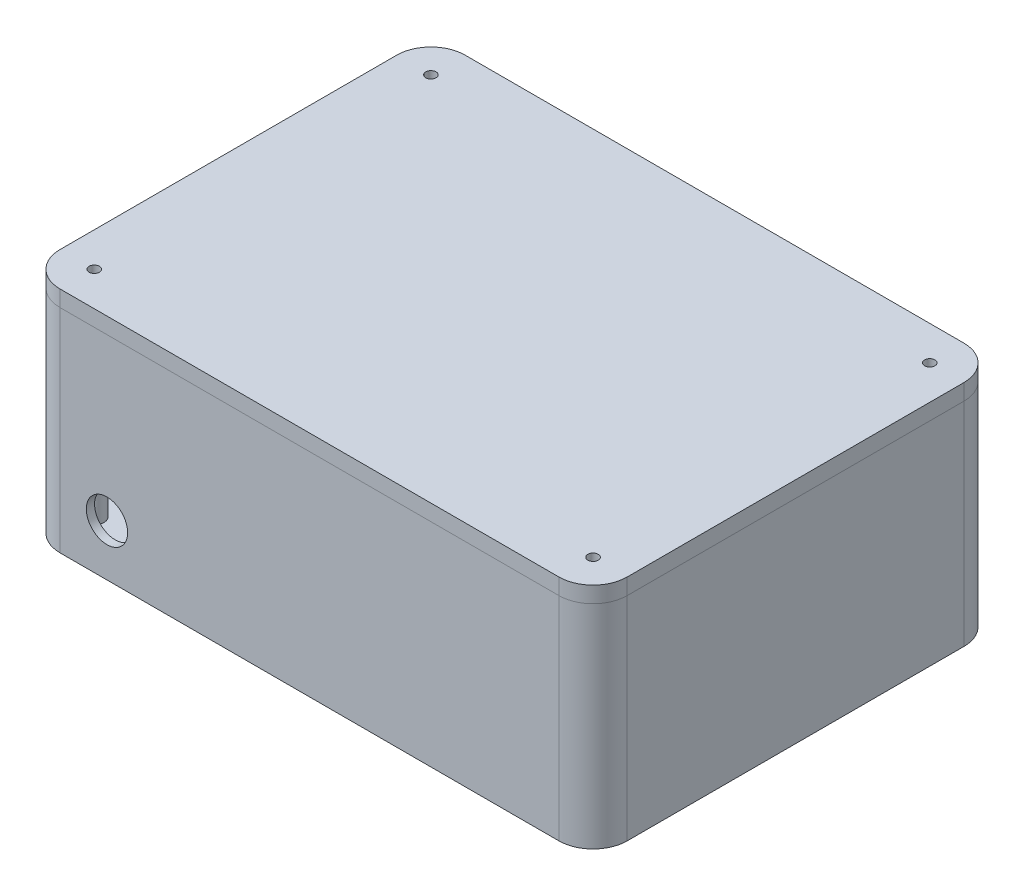
from build123d import *

# Parameters (mm, degrees)
SIDES_DEPTH        = 60.96
SKETCH1_R          = 2.9845
SKETCH1_R_2        = 1.5875
SIDES_2_DEPTH      = 60.96
SIDES_3_DEPTH      = 60.96
SIDES_4_DEPTH      = 60.96
SIDES_5_DEPTH      = 60.96
BOTTOM_DEPTH       = 4.318
SKETCH3_R          = 1.5875
LID_DEPTH          = 4.953
SKETCH6_R          = 1.778
MX150_CUTS_DEPTH   = 2.54
SKETCH7_R          = 6.35
CUT_EXTRUDE1_DEPTH = 2.54


with BuildPart() as part:
    # Sketch1 → Sides (new body)
    with BuildSketch(Plane(origin=(0, 0, 0), x_dir=(1, 0, 0), z_dir=(0, 1, 0))):
        with BuildLine():
            Line((-76.6347, 62.23), (76.6347, 62.23))
            ThreePointArc((76.6347, 62.23), (84.059321202, 59.154621202), (87.1347, 51.73))
            Line((87.1347, 51.73), (87.1347, -51.73))
            ThreePointArc((87.1347, -51.73), (84.059321202, -59.154621202), (76.6347, -62.23))
            Line((76.6347, -62.23), (-76.6347, -62.23))
            ThreePointArc((-76.6347, -62.23), (-84.059321202, -59.154621202), (-87.1347, -51.73))
            Line((-87.1347, -51.73), (-87.1347, 51.73))
            ThreePointArc((-87.1347, 51.73), (-84.059321202, 59.154621202), (-76.6347, 62.23))
        make_face()
        with BuildLine():
            ThreePointArc((-76.6347, 59.69), (-82.263269978, 57.358569978), (-84.5947, 51.73))
            Line((-84.5947, 51.73), (-84.5947, -51.73))
            ThreePointArc((-84.5947, -51.73), (-82.263269978, -57.358569978), (-76.6347, -59.69))
            Line((-76.6347, -59.69), (76.6347, -59.69))
            ThreePointArc((76.6347, -59.69), (82.263269978, -57.358569978), (84.5947, -51.73))
            Line((84.5947, -51.73), (84.5947, 51.73))
            ThreePointArc((84.5947, 51.73), (82.263269978, 57.358569978), (76.6347, 59.69))
            Line((76.6347, 59.69), (-76.6347, 59.69))
        make_face(mode=Mode.SUBTRACT)
    extrude(amount=SIDES_DEPTH)

    # Sketch2 → Bottom (add)
    with BuildSketch(Plane(origin=(0, 0, 0), x_dir=(1, 0, 0), z_dir=(0, 1, 0))):
        with BuildLine():
            Line((-76.6347, -62.23), (76.6347, -62.23))
            ThreePointArc((76.6347, -62.23), (84.059321202, -59.154621202), (87.1347, -51.73))
            Line((87.1347, -51.73), (87.1347, 51.73))
            ThreePointArc((87.1347, 51.73), (84.059321202, 59.154621202), (76.6347, 62.23))
            Line((76.6347, 62.23), (-76.6347, 62.23))
            ThreePointArc((-76.6347, 62.23), (-84.059321202, 59.154621202), (-87.1347, 51.73))
            Line((-87.1347, 51.73), (-87.1347, -51.73))
            ThreePointArc((-87.1347, -51.73), (-84.059321202, -59.154621202), (-76.6347, -62.23))
        make_face()
    extrude(amount=-BOTTOM_DEPTH)

    # Sketch6 → MX150 Cuts (cut)
    with BuildSketch(Plane.ZY.offset(87.1347)):
        with Locations((4.74, 41.91)):
            Circle(SKETCH6_R)
        with Locations((44.11, 41.91)):
            Circle(SKETCH6_R)
        with Locations((-44.11, 41.91)):
            Circle(SKETCH6_R)
        with Locations((-4.74, 41.91)):
            Circle(SKETCH6_R)
        with Locations((-44.11, 13.97)):
            Circle(SKETCH6_R)
        with Locations((-4.74, 13.97)):
            Circle(SKETCH6_R)
        with Locations((4.74, 13.97)):
            Circle(SKETCH6_R)
        with Locations((44.11, 13.97)):
            Circle(SKETCH6_R)
        with BuildLine():
            Line((9.693, 45.212), (9.693, 38.608))
            ThreePointArc((9.693, 38.608), (11.366884746, 34.566884746), (15.408, 32.893))
            Line((15.408, 32.893), (33.442, 32.893))
            ThreePointArc((33.442, 32.893), (37.483115254, 34.566884746), (39.157, 38.608))
            Line((39.157, 38.608), (39.157, 45.212))
            ThreePointArc((39.157, 45.212), (39.074695768, 46.178417808), (38.830153673, 47.117))
            Line((38.830153673, 47.117), (40.234514304, 47.613516463))
            ThreePointArc((40.234514304, 47.613516463), (41.240758699, 49.720427524), (39.133847638, 50.726671918))
            Line((39.133847638, 50.726671918), (36.739112672, 49.880005252))
            ThreePointArc((36.739112672, 49.880005252), (35.171678437, 50.658965899), (33.442, 50.927))
            Line((33.442, 50.927), (27.9175, 50.927))
            ThreePointArc((27.9175, 50.927), (27.359538418, 52.274038418), (26.0125, 52.832))
            Line((26.0125, 52.832), (22.8375, 52.832))
            ThreePointArc((22.8375, 52.832), (21.490461582, 52.274038418), (20.9325, 50.927))
            Line((20.9325, 50.927), (15.408, 50.927))
            ThreePointArc((15.408, 50.927), (13.678321563, 50.658965899), (12.110887328, 49.880005252))
            Line((12.110887328, 49.880005252), (9.716152362, 50.726671918))
            ThreePointArc((9.716152362, 50.726671918), (7.609241301, 49.720427524), (8.615485696, 47.613516463))
            Line((8.615485696, 47.613516463), (10.019846327, 47.117))
            ThreePointArc((10.019846327, 47.117), (9.775304232, 46.178417808), (9.693, 45.212))
        make_face()
        with BuildLine():
            Line((-39.157, 45.212), (-39.157, 38.608))
            ThreePointArc((-39.157, 38.608), (-37.483115254, 34.566884746), (-33.442, 32.893))
            Line((-33.442, 32.893), (-15.408, 32.893))
            ThreePointArc((-15.408, 32.893), (-11.366884746, 34.566884746), (-9.693, 38.608))
            Line((-9.693, 38.608), (-9.693, 45.212))
            ThreePointArc((-9.693, 45.212), (-9.775304232, 46.178417808), (-10.019846327, 47.117))
            Line((-10.019846327, 47.117), (-8.615485696, 47.613516463))
            ThreePointArc((-8.615485696, 47.613516463), (-7.609241301, 49.720427524), (-9.716152362, 50.726671918))
            Line((-9.716152362, 50.726671918), (-12.110887328, 49.880005252))
            ThreePointArc((-12.110887328, 49.880005252), (-13.678321563, 50.658965899), (-15.408, 50.927))
            Line((-15.408, 50.927), (-20.9325, 50.927))
            ThreePointArc((-20.9325, 50.927), (-21.490461582, 52.274038418), (-22.8375, 52.832))
            Line((-22.8375, 52.832), (-26.0125, 52.832))
            ThreePointArc((-26.0125, 52.832), (-27.359538418, 52.274038418), (-27.9175, 50.927))
            Line((-27.9175, 50.927), (-33.442, 50.927))
            ThreePointArc((-33.442, 50.927), (-35.171678437, 50.658965899), (-36.739112672, 49.880005252))
            Line((-36.739112672, 49.880005252), (-39.133847638, 50.726671918))
            ThreePointArc((-39.133847638, 50.726671918), (-41.240758699, 49.720427524), (-40.234514304, 47.613516463))
            Line((-40.234514304, 47.613516463), (-38.830153673, 47.117))
            ThreePointArc((-38.830153673, 47.117), (-39.074695768, 46.178417808), (-39.157, 45.212))
        make_face()
        with BuildLine():
            Line((-39.157, 17.272), (-39.157, 10.668))
            ThreePointArc((-39.157, 10.668), (-37.483115254, 6.626884746), (-33.442, 4.953))
            Line((-33.442, 4.953), (-15.408, 4.953))
            ThreePointArc((-15.408, 4.953), (-11.366884746, 6.626884746), (-9.693, 10.668))
            Line((-9.693, 10.668), (-9.693, 17.272))
            ThreePointArc((-9.693, 17.272), (-9.775304232, 18.238417808), (-10.019846327, 19.177))
            Line((-10.019846327, 19.177), (-8.615485696, 19.673516463))
            ThreePointArc((-8.615485696, 19.673516463), (-7.609241301, 21.780427524), (-9.716152362, 22.786671918))
            Line((-9.716152362, 22.786671918), (-12.110887328, 21.940005252))
            ThreePointArc((-12.110887328, 21.940005252), (-13.678321563, 22.718965899), (-15.408, 22.987))
            Line((-15.408, 22.987), (-20.9325, 22.987))
            ThreePointArc((-20.9325, 22.987), (-21.490461582, 24.334038418), (-22.8375, 24.892))
            Line((-22.8375, 24.892), (-26.0125, 24.892))
            ThreePointArc((-26.0125, 24.892), (-27.359538418, 24.334038418), (-27.9175, 22.987))
            Line((-27.9175, 22.987), (-33.442, 22.987))
            ThreePointArc((-33.442, 22.987), (-35.171678437, 22.718965899), (-36.739112672, 21.940005252))
            Line((-36.739112672, 21.940005252), (-39.133847638, 22.786671918))
            ThreePointArc((-39.133847638, 22.786671918), (-41.240758699, 21.780427524), (-40.234514304, 19.673516463))
            Line((-40.234514304, 19.673516463), (-38.830153673, 19.177))
            ThreePointArc((-38.830153673, 19.177), (-39.074695768, 18.238417808), (-39.157, 17.272))
        make_face()
        with BuildLine():
            Line((9.693, 17.272), (9.693, 10.668))
            ThreePointArc((9.693, 10.668), (11.366884746, 6.626884746), (15.408, 4.953))
            Line((15.408, 4.953), (33.442, 4.953))
            ThreePointArc((33.442, 4.953), (37.483115254, 6.626884746), (39.157, 10.668))
            Line((39.157, 10.668), (39.157, 17.272))
            ThreePointArc((39.157, 17.272), (39.074695768, 18.238417808), (38.830153673, 19.177))
            Line((38.830153673, 19.177), (40.234514304, 19.673516463))
            ThreePointArc((40.234514304, 19.673516463), (41.240758699, 21.780427524), (39.133847638, 22.786671918))
            Line((39.133847638, 22.786671918), (36.739112672, 21.940005252))
            ThreePointArc((36.739112672, 21.940005252), (35.171678437, 22.718965899), (33.442, 22.987))
            Line((33.442, 22.987), (27.9175, 22.987))
            ThreePointArc((27.9175, 22.987), (27.359538418, 24.334038418), (26.0125, 24.892))
            Line((26.0125, 24.892), (22.8375, 24.892))
            ThreePointArc((22.8375, 24.892), (21.490461582, 24.334038418), (20.9325, 22.987))
            Line((20.9325, 22.987), (15.408, 22.987))
            ThreePointArc((15.408, 22.987), (13.678321563, 22.718965899), (12.110887328, 21.940005252))
            Line((12.110887328, 21.940005252), (9.716152362, 22.786671918))
            ThreePointArc((9.716152362, 22.786671918), (7.609241301, 21.780427524), (8.615485696, 19.673516463))
            Line((8.615485696, 19.673516463), (10.019846327, 19.177))
            ThreePointArc((10.019846327, 19.177), (9.775304232, 18.238417808), (9.693, 17.272))
        make_face()
    extrude(amount=-MX150_CUTS_DEPTH, mode=Mode.SUBTRACT)

    # Sketch7 → Cut-Extrude1 (cut)
    with BuildSketch(Plane.XY.offset(62.23)):
        with Locations((-62.2202, 11.43)):
            Circle(SKETCH7_R)
    extrude(amount=-CUT_EXTRUDE1_DEPTH, mode=Mode.SUBTRACT)


with BuildPart() as body_2:
    # Sketch1 → Sides 2 (new body)
    with BuildSketch(Plane(origin=(0, 0, 0), x_dir=(1, 0, 0), z_dir=(0, 1, 0))):
        with Locations((-76.6347, 51.73)):
            Circle(SKETCH1_R)
        with Locations((-76.6347, 51.73)):
            Circle(SKETCH1_R_2, mode=Mode.SUBTRACT)
    extrude(amount=SIDES_2_DEPTH)


with BuildPart() as body_3:
    # Sketch1 → Sides 3 (new body)
    with BuildSketch(Plane(origin=(0, 0, 0), x_dir=(1, 0, 0), z_dir=(0, 1, 0))):
        with Locations((76.6347, 51.73)):
            Circle(SKETCH1_R)
        with Locations((76.6347, 51.73)):
            Circle(SKETCH1_R_2, mode=Mode.SUBTRACT)
    extrude(amount=SIDES_3_DEPTH)


with BuildPart() as body_4:
    # Sketch1 → Sides 4 (new body)
    with BuildSketch(Plane(origin=(0, 0, 0), x_dir=(1, 0, 0), z_dir=(0, 1, 0))):
        with Locations((76.6347, -51.73)):
            Circle(SKETCH1_R)
        with Locations((76.6347, -51.73)):
            Circle(SKETCH1_R_2, mode=Mode.SUBTRACT)
    extrude(amount=SIDES_4_DEPTH)


with BuildPart() as body_5:
    # Sketch1 → Sides 5 (new body)
    with BuildSketch(Plane(origin=(0, 0, 0), x_dir=(1, 0, 0), z_dir=(0, 1, 0))):
        with Locations((-76.6347, -51.73)):
            Circle(SKETCH1_R)
        with Locations((-76.6347, -51.73)):
            Circle(SKETCH1_R_2, mode=Mode.SUBTRACT)
    extrude(amount=SIDES_5_DEPTH)


with BuildPart() as body_6:
    # Sketch3 → Lid (new body)
    with BuildSketch(Plane(origin=(0, 60.96, 0), x_dir=(1, 0, 0), z_dir=(0, 1, 0))):
        with BuildLine():
            Line((-87.1347, 51.73), (-87.1347, -51.73))
            ThreePointArc((-87.1347, -51.73), (-84.059321202, -59.154621202), (-76.6347, -62.23))
            Line((-76.6347, -62.23), (76.6347, -62.23))
            ThreePointArc((76.6347, -62.23), (84.059321202, -59.154621202), (87.1347, -51.73))
            Line((87.1347, -51.73), (87.1347, 51.73))
            ThreePointArc((87.1347, 51.73), (84.059321202, 59.154621202), (76.6347, 62.23))
            Line((76.6347, 62.23), (-76.6347, 62.23))
            ThreePointArc((-76.6347, 62.23), (-84.059321202, 59.154621202), (-87.1347, 51.73))
        make_face()
        with Locations((76.6347, 51.73)):
            Circle(SKETCH3_R, mode=Mode.SUBTRACT)
        with Locations((76.6347, -51.73)):
            Circle(SKETCH3_R, mode=Mode.SUBTRACT)
        with Locations((-76.6347, -51.73)):
            Circle(SKETCH3_R, mode=Mode.SUBTRACT)
        with Locations((-76.6347, 51.73)):
            Circle(SKETCH3_R, mode=Mode.SUBTRACT)
    extrude(amount=LID_DEPTH)


solid = Compound([part.part, body_2.part, body_3.part, body_4.part, body_5.part, body_6.part])
